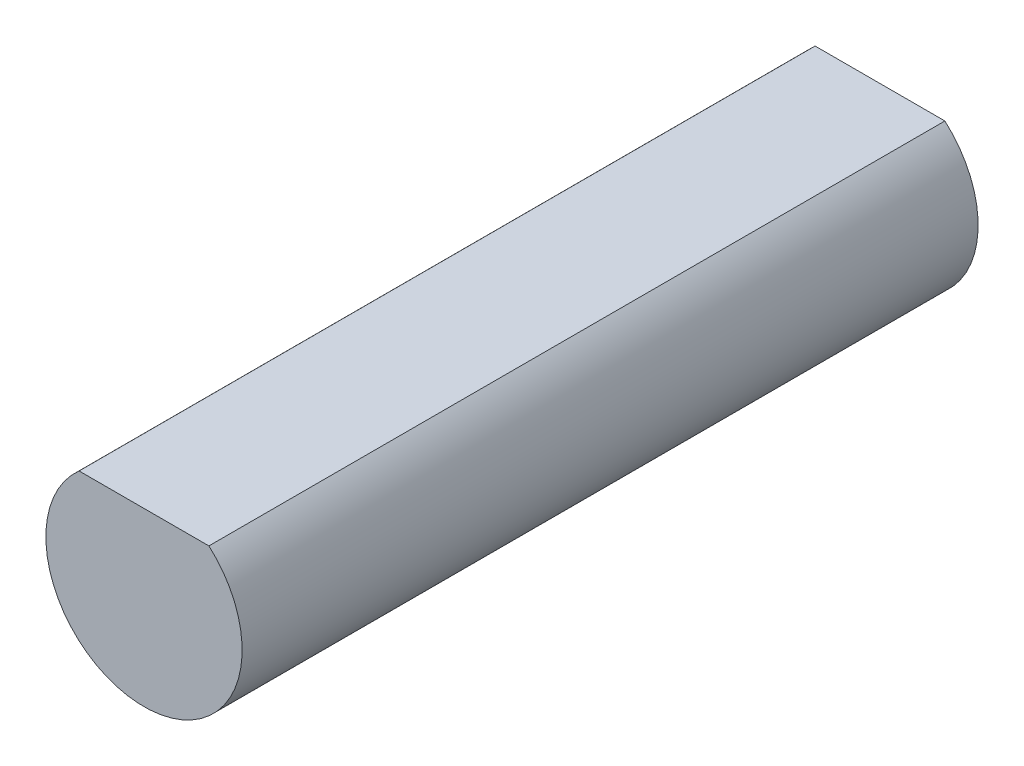
from build123d import *

# Parameters (mm, degrees)
BOSS_EXTRUDE1_DEPTH = 15


with BuildPart() as part:
    # Sketch1 → Boss-Extrude1 (new body)
    with BuildSketch(Plane.XY):
        with BuildLine():
            Line((1.322875656, 1.5), (-1.322875656, 1.5))
            ThreePointArc((-1.322875656, 1.5), (0, -2), (1.322875656, 1.5))
        make_face()
    extrude(amount=-BOSS_EXTRUDE1_DEPTH)


solid = part.part
